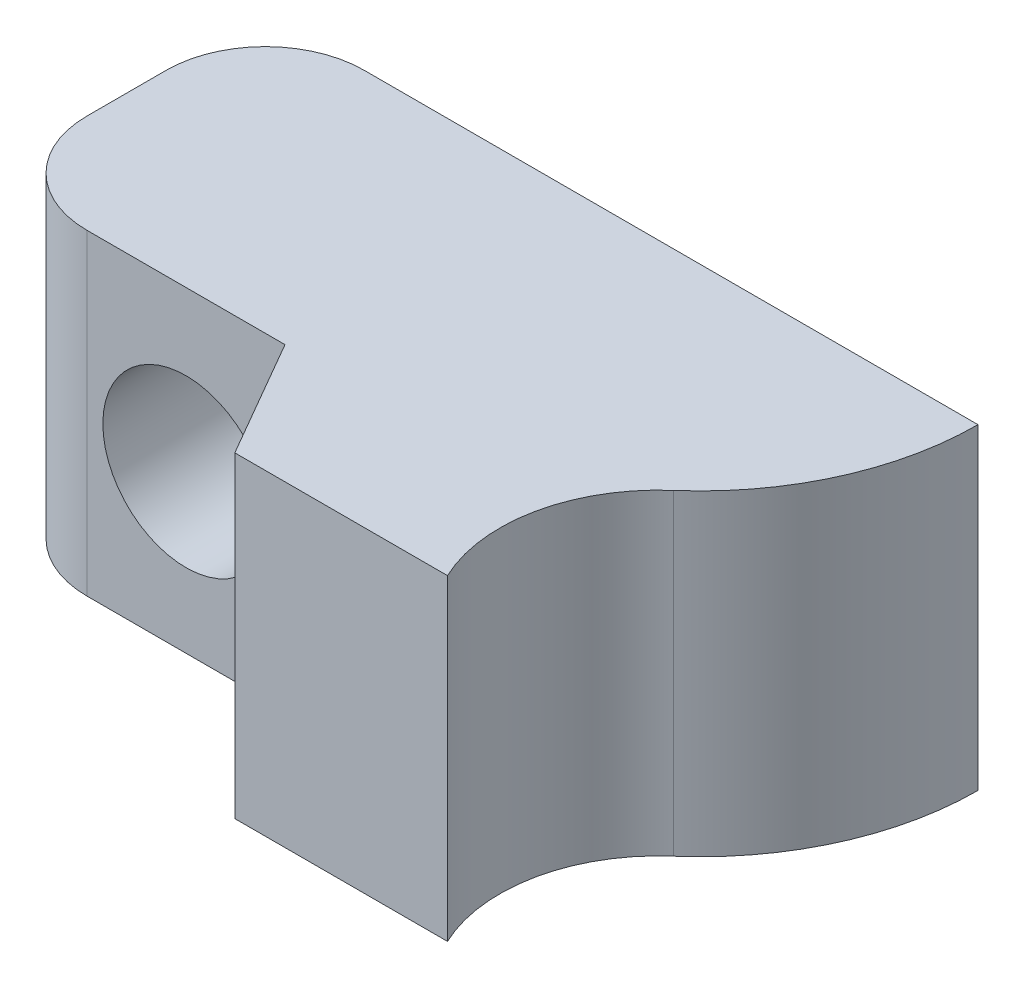
from build123d import *

# Parameters (mm, degrees)
SKETCH1_W               = 18
SKETCH1_H               = 8
SKETCH1_R               = 1.6
BOSS_EXTRUDE1_DEPTH     = 10
CUT_EXTRUDE1_DEPTH      = 1
CUT_EXTRUDE1_DEPTH_BACK = 9
CUT_EXTRUDE3_DEPTH      = 1
CUT_EXTRUDE3_DEPTH_BACK = 9
FILLET1_R               = 2.5
SKETCH4_R               = 2.1
CUT_EXTRUDE4_DEPTH      = 4
CUT_EXTRUDE4_DEPTH_BACK = 5


with BuildPart() as part:
    # Sketch1 → Boss-Extrude1 (new body)
    with BuildSketch(Plane.XY):
        with Locations((4, 0.027746394)):
            Rectangle(SKETCH1_W, SKETCH1_H)
        Circle(SKETCH1_R, mode=Mode.SUBTRACT)
    extrude(amount=BOSS_EXTRUDE1_DEPTH)

    # Sketch2 → Cut-Extrude1 (cut, two sides)
    with BuildSketch(Plane.XZ.offset(3.972253606)) as cut_extrude1_sk:
        with BuildLine():
            Line((13.221576202, 12.297519941), (13, 0))
            ThreePointArc((13, 0), (12.370590218, 2.900961957), (10.595548492, 5.280239962))
            ThreePointArc((10.595548492, 5.280239962), (9.475303393, 9.699461467), (13.221576202, 12.297519941))
        make_face()
    extrude(amount=CUT_EXTRUDE1_DEPTH, mode=Mode.SUBTRACT)
    extrude(cut_extrude1_sk.sketch, amount=-CUT_EXTRUDE1_DEPTH_BACK, mode=Mode.SUBTRACT)

    # Sketch3 → Cut-Extrude3 (cut, two sides)
    with BuildSketch(Plane(origin=(0, 4.027746394, 0), x_dir=(1, 0, 0), z_dir=(0, 1, 0))) as cut_extrude3_sk:
        Polygon((-5, -7), (2.5, -7), (4.232050808, -10), (-5, -10), align=None)
    extrude(amount=CUT_EXTRUDE3_DEPTH, mode=Mode.SUBTRACT)
    extrude(cut_extrude3_sk.sketch, amount=-CUT_EXTRUDE3_DEPTH_BACK, mode=Mode.SUBTRACT)

    # Fillet1
    fillet1_edges = [part.edges().sort_by_distance(p)[0] for p in [
        (-5, 0.027746394, 7),
        (-5, 0.027746394, 0),
    ]]
    fillet(fillet1_edges, radius=FILLET1_R)

    # Sketch4 → Cut-Extrude4 (cut, two sides)
    with BuildSketch(Plane.XY.offset(7)) as cut_extrude4_sk:
        Circle(SKETCH4_R)
    extrude(amount=CUT_EXTRUDE4_DEPTH, mode=Mode.SUBTRACT)
    extrude(cut_extrude4_sk.sketch, amount=-CUT_EXTRUDE4_DEPTH_BACK, mode=Mode.SUBTRACT)


solid = part.part
